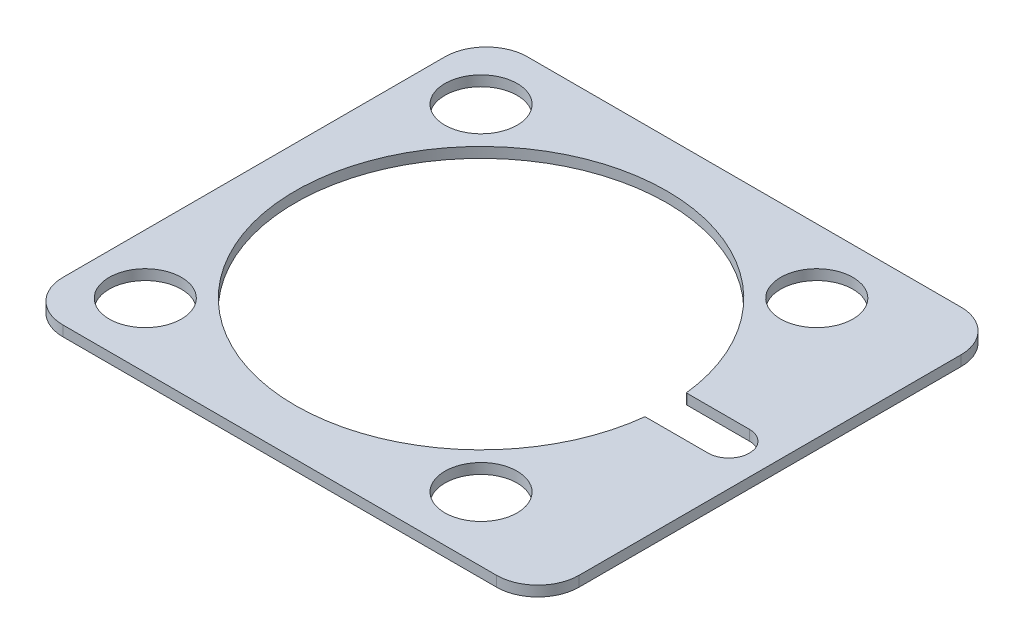
from build123d import *

# Parameters (mm, degrees)
SKETCH1_R           = 3.5
BOSS_EXTRUDE1_DEPTH = 1


with BuildPart() as part:
    # Sketch1 → Boss-Extrude1 (new body)
    with BuildSketch(Plane(origin=(0, 0, 0), x_dir=(1, 0, 0), z_dir=(0, 1, 0))):
        with BuildLine():
            Line((-21, -22.5), (21, -22.5))
            ThreePointArc((21, -22.5), (23.828427125, -21.328427125), (25, -18.5))
            Line((25, -18.5), (25, 18.5))
            ThreePointArc((25, 18.5), (23.828427125, 21.328427125), (21, 22.5))
            Line((21, 22.5), (-21, 22.5))
            ThreePointArc((-21, 22.5), (-23.828427125, 21.328427125), (-25, 18.5))
            Line((-25, 18.5), (-25, -18.5))
            ThreePointArc((-25, -18.5), (-23.828427125, -21.328427125), (-21, -22.5))
        make_face()
        with Locations((-19.263455967, 16.263455967)):
            Circle(SKETCH1_R, mode=Mode.SUBTRACT)
        with Locations((13.263455967, 16.263455967)):
            Circle(SKETCH1_R, mode=Mode.SUBTRACT)
        with Locations((13.263455967, -16.263455967)):
            Circle(SKETCH1_R, mode=Mode.SUBTRACT)
        with Locations((-19.263455967, -16.263455967)):
            Circle(SKETCH1_R, mode=Mode.SUBTRACT)
        with BuildLine():
            Line((15, 2), (21, 2))
            ThreePointArc((21, 2), (23, 0), (21, -2))
            Line((21, -2), (15, -2))
            ThreePointArc((15, -2), (14.944422982, -1.99922765), (14.888888889, -1.996911195))
            ThreePointArc((14.888888889, -1.996911195), (-21, 0), (14.888888889, 1.996911195))
            ThreePointArc((14.888888889, 1.996911195), (14.944422982, 1.99922765), (15, 2))
        make_face(mode=Mode.SUBTRACT)
    extrude(amount=BOSS_EXTRUDE1_DEPTH)


solid = part.part
